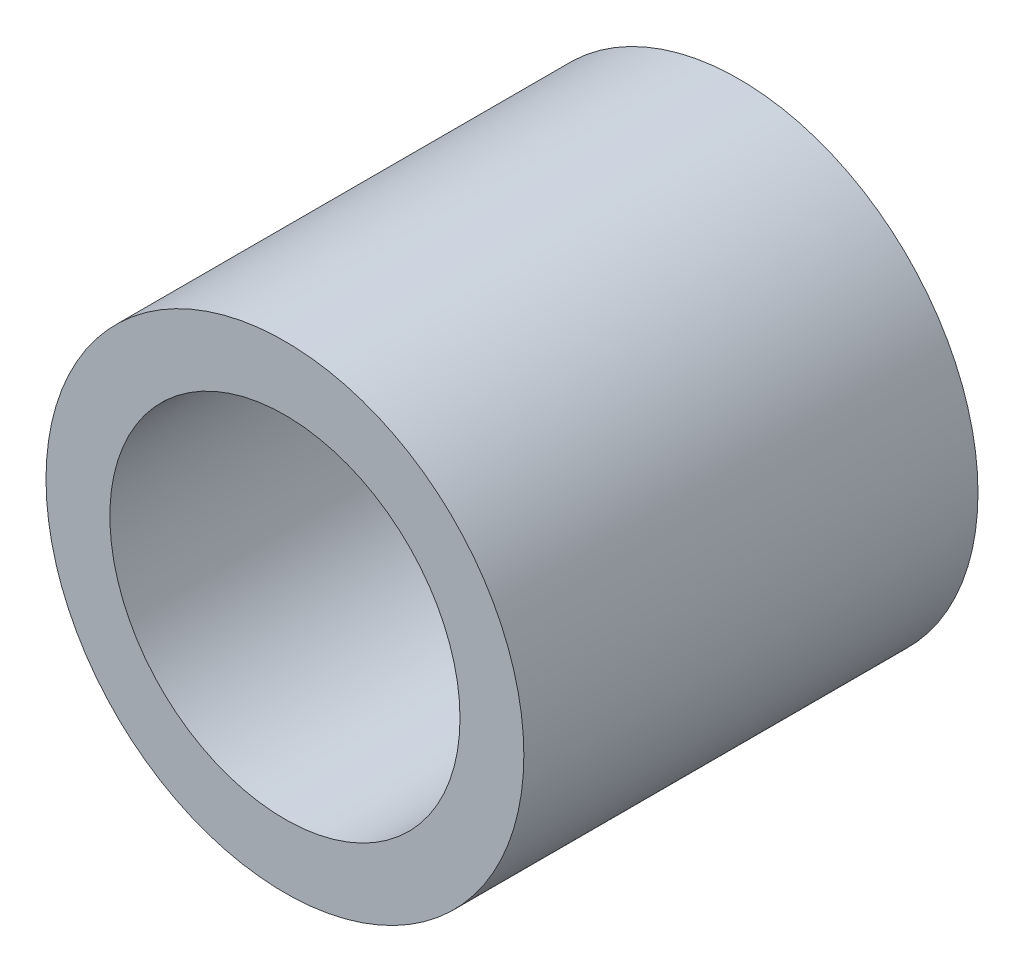
from build123d import *

# Parameters (mm, degrees)
SKETCH1_R                = 4.6101
BOSS_EXTRUDE1_DEPTH      = 8.763
H_0_266_DIAMETER_HOLE1_D = 6.7564


with BuildPart() as part:
    # Sketch1 → Boss-Extrude1 (new body)
    with BuildSketch(Plane.XY):
        Circle(SKETCH1_R)
    extrude(amount=-BOSS_EXTRUDE1_DEPTH)

    # H (0.266) Diameter Hole1 (through all)
    with Locations(Plane.XY):
        with Locations((0, 0)):
            Hole(H_0_266_DIAMETER_HOLE1_D / 2)


solid = part.part
